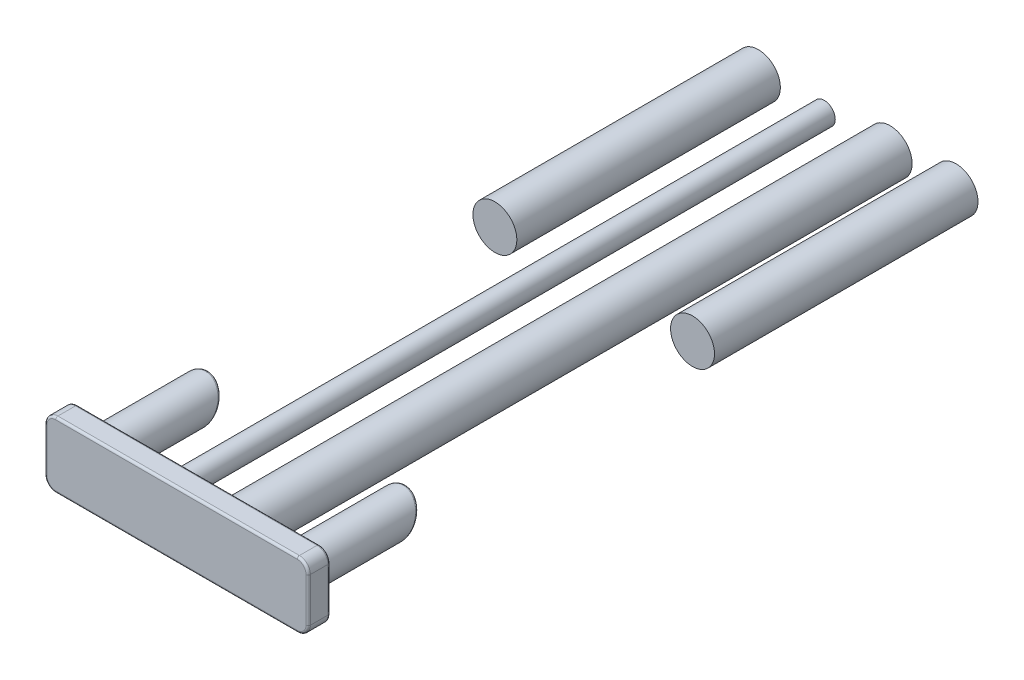
from build123d import *

# Parameters (mm, degrees)
SKETCH1_R             = 0.25
BOSS_EXTRUDE1_DEPTH   = 15
SKETCH1_R_2           = 0.5
BOSS_EXTRUDE1_2_DEPTH = 15
BOSS_EXTRUDE1_3_DEPTH = 15
BOSS_EXTRUDE1_4_DEPTH = 15
SKETCH2_R             = 0.25
CUT_EXTRUDE1_DEPTH    = 12
SKETCH3_R             = 0.797194258
SKETCH3_R_2           = 0.805322926
CUT_EXTRUDE2_DEPTH    = 9
SKETCH4_W             = 6
SKETCH4_H             = 1.5
BOSS_EXTRUDE2_DEPTH   = 0.5
SKETCH5_R             = 0.45
BOSS_EXTRUDE3_DEPTH   = 2.5
CUT_EXTRUDE3_START    = -1.5
CUT_EXTRUDE3_DEPTH    = 2.5
CUT_EXTRUDE5_START    = 1.5
CUT_EXTRUDE5_DEPTH    = 2.5
FILLET1_R             = 0.25
FILLET2_R             = 0.05


with BuildPart() as part:
    # Sketch1 → Boss-Extrude1 (new body)
    with BuildSketch(Plane.XY):
        with Locations((-0.75, 0)):
            Circle(SKETCH1_R)
    extrude(amount=BOSS_EXTRUDE1_DEPTH)



with BuildPart() as body_2:
    # Sketch1 → Boss-Extrude1 2 (new body)
    with BuildSketch(Plane.XY):
        with Locations((0.75, 0)):
            Circle(SKETCH1_R_2)
    extrude(amount=BOSS_EXTRUDE1_2_DEPTH)

    # Sketch2 → Cut-Extrude1 (cut)
    with BuildSketch(Plane.XY.offset(15)):
        with Locations((0.75, 0)):
            Circle(SKETCH2_R)
    extrude(amount=-CUT_EXTRUDE1_DEPTH, mode=Mode.SUBTRACT)


with BuildPart() as body_3:
    # Sketch1 → Boss-Extrude1 3 (new body)
    with BuildSketch(Plane.XY):
        with Locations((2.25, 0)):
            Circle(SKETCH1_R_2)
    extrude(amount=BOSS_EXTRUDE1_3_DEPTH)


with BuildPart() as body_4:
    # Sketch1 → Boss-Extrude1 4 (new body)
    with BuildSketch(Plane.XY):
        with Locations((-2.25, 0)):
            Circle(SKETCH1_R_2)
    extrude(amount=BOSS_EXTRUDE1_4_DEPTH)


with BuildPart() as cut_extrude2_tool:
    # Sketch3 → Cut-Extrude2 (new body)
    with BuildSketch(Plane.XY.offset(15)):
        with Locations((-2.25, 0)):
            Circle(SKETCH3_R)
        with Locations((2.25, 0)):
            Circle(SKETCH3_R_2)
    extrude(amount=-CUT_EXTRUDE2_DEPTH)


with BuildPart() as body_3_1:
    add(body_3.part)

    # Cut-Extrude2: cut by cut_extrude2_tool
    add(cut_extrude2_tool.part, mode=Mode.SUBTRACT)


with BuildPart() as body_4_1:
    add(body_4.part)

    # Cut-Extrude2: cut by cut_extrude2_tool
    add(cut_extrude2_tool.part, mode=Mode.SUBTRACT)


with BuildPart() as part_1:
    add(part.part)

    add(body_2.part)  # Boss-Extrude2 merges body 2
    # Sketch4 → Boss-Extrude2 (add)
    with BuildSketch(Plane.XY.offset(15)):
        Rectangle(SKETCH4_W, SKETCH4_H)
    extrude(amount=BOSS_EXTRUDE2_DEPTH)

    # Sketch5 → Boss-Extrude3 (add)
    with BuildSketch(Plane(origin=(0, 0, 15), x_dir=(-1, 0, 0), z_dir=(0, 0, -1))):
        with Locations((2.25, 0)):
            Circle(SKETCH5_R)
        with Locations((-2.25, 0)):
            Circle(SKETCH5_R)
    extrude(amount=BOSS_EXTRUDE3_DEPTH)

    # Sketch6 → Cut-Extrude3 (cut)
    with BuildSketch(Plane(origin=(0, 0, 0), x_dir=(0, 0, -1), z_dir=(1, 0, 0)).offset(CUT_EXTRUDE3_START)):
        Polygon((-12.5, 0.45), (-12.5, -0.45), (-13, -0.45), align=None)
    extrude(amount=-CUT_EXTRUDE3_DEPTH, mode=Mode.SUBTRACT)

    # Sketch7 → Cut-Extrude5 (cut)
    with BuildSketch(Plane(origin=(0, 0, 0), x_dir=(0, 0, -1), z_dir=(1, 0, 0)).offset(CUT_EXTRUDE5_START)):
        Polygon((-12.5, 0.45), (-13, -0.45), (-12.5, -0.45), align=None)
    extrude(amount=CUT_EXTRUDE5_DEPTH, mode=Mode.SUBTRACT)

    # Fillet1
    fillet1_edges = [part_1.edges().sort_by_distance(p)[0] for p in [
        (-3, -0.75, 15.25),
        (-3, 0.75, 15.25),
        (3, -0.75, 15.25),
        (3, 0.75, 15.25),
    ]]
    fillet(fillet1_edges, radius=FILLET1_R)

    # Fillet2
    fillet2_edges = [part_1.edges().sort_by_distance(p)[0] for p in [
        (-2.926776695, 0.676776695, 15.5),
        (0, 0.75, 15.5),
        (2.926776695, 0.676776695, 15.5),
        (3, 0, 15.5),
        (2.926776695, -0.676776695, 15.5),
        (0, -0.75, 15.5),
        (-2.926776695, -0.676776695, 15.5),
        (-3, 0, 15.5),
        (2.7, 0, 15),
        (0.25, 0, 15),
        (2.926776695, -0.676776695, 15),
        (3, 0, 15),
        (2.926776695, 0.676776695, 15),
        (0, 0.75, 15),
        (-2.926776695, 0.676776695, 15),
        (-3, 0, 15),
        (-2.926776695, -0.676776695, 15),
        (0, -0.75, 15),
        (-1, 0, 15),
        (-1.8, 0, 15),
        (-2.578645848, -0.307395359, 12.920775199),
        (1.921354152, -0.307395359, 12.920775199),
    ]]
    fillet(fillet2_edges, radius=FILLET2_R)


solid = Compound([body_3_1.part, body_4_1.part, part_1.part])
